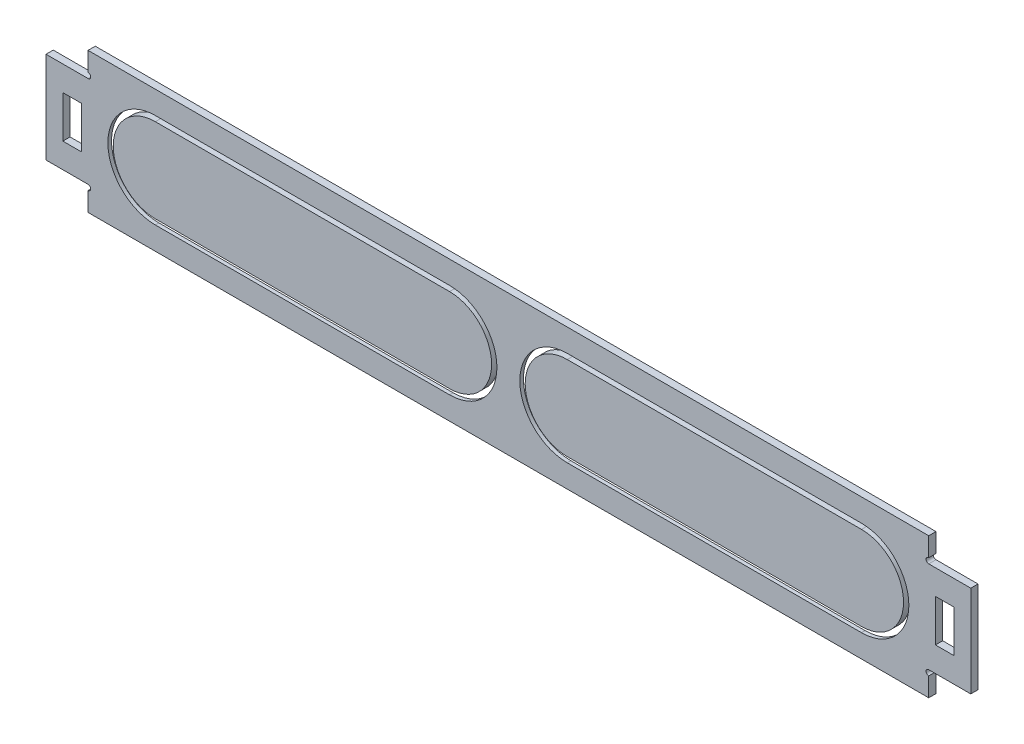
from build123d import *

# Parameters (mm, degrees)
SKETCH1_W           = 22
SKETCH1_H           = 50
BOSS_EXTRUDE1_DEPTH = 4.3


with BuildPart() as part:
    # Sketch1 → Boss-Extrude1 (new body, symmetric)
    with BuildSketch(Plane.XY):
        with BuildLine():
            Line((-500, 83.5), (500, 83.5))
            Line((500, 83.5), (500, 60.85))
            ThreePointArc((500, 60.85), (496.825, 57.675), (500, 54.5))
            Line((500, 54.5), (550, 54.5))
            Line((550, 54.5), (550, -54.5))
            Line((550, -54.5), (500, -54.5))
            ThreePointArc((500, -54.5), (496.825, -57.675), (500, -60.85))
            Line((500, -60.85), (500, -83.5))
            Line((500, -83.5), (-500, -83.5))
            Line((-500, -83.5), (-500, -60.85))
            ThreePointArc((-500, -60.85), (-496.825, -57.675), (-500, -54.5))
            Line((-500, -54.5), (-550, -54.5))
            Line((-550, -54.5), (-550, 54.5))
            Line((-550, 54.5), (-500, 54.5))
            ThreePointArc((-500, 54.5), (-496.825, 57.675), (-500, 60.85))
            Line((-500, 60.85), (-500, 83.5))
        make_face()
        with Locations((519, 0)):
            Rectangle(SKETCH1_W, SKETCH1_H, mode=Mode.SUBTRACT)
        with Locations((-519, 0)):
            Rectangle(SKETCH1_W, SKETCH1_H, mode=Mode.SUBTRACT)
    extrude(amount=BOSS_EXTRUDE1_DEPTH, both=True)

    # Cut-Sweep1: sweep along a path in Sketch2
    with BuildLine(Plane.XY) as cut_sweep1_path:
        Line((-420, 50), (-70, 50))
        ThreePointArc((-70, 50), (-20, 0), (-70, -50))
        Line((-70, -50), (-420, -50))
        ThreePointArc((-420, -50), (-470, 0), (-420, 50))
    # Sketch3 → Cut-Sweep1 (sweep, cut)
    with BuildSketch(Plane(origin=(-420, 0, 0), x_dir=(0, 0, -1), z_dir=(1, 0, 0))):
        Polygon((0, 62.015479753), (0, 57.679593212), (0, 56.365479753), (-6, 56.365479753), (-6, 50.015479753), (6, 50.015479753), (6, 62.015479753), align=None)
    sweep(path=cut_sweep1_path.line, mode=Mode.SUBTRACT)

    # Cut-Sweep2: sweep along a path in Sketch2_3
    with BuildLine(Plane.XY) as cut_sweep2_path:
        Line((420, 50), (70, 50))
        ThreePointArc((70, 50), (20, 0), (70, -50))
        Line((70, -50), (420, -50))
        ThreePointArc((420, -50), (470, 0), (420, 50))
    # Sketch4 → Cut-Sweep2 (sweep, cut)
    with BuildSketch(Plane(origin=(420, 0, 0), x_dir=(0, 0, -1), z_dir=(1, 0, 0))):
        Polygon((-6, 50.015479753), (-6, 56.365479753), (0, 56.365479753), (0, 62.015479753), (6, 62.015479753), (6, 50.015479753), align=None)
    sweep(path=cut_sweep2_path.line, mode=Mode.SUBTRACT)


solid = part.part
